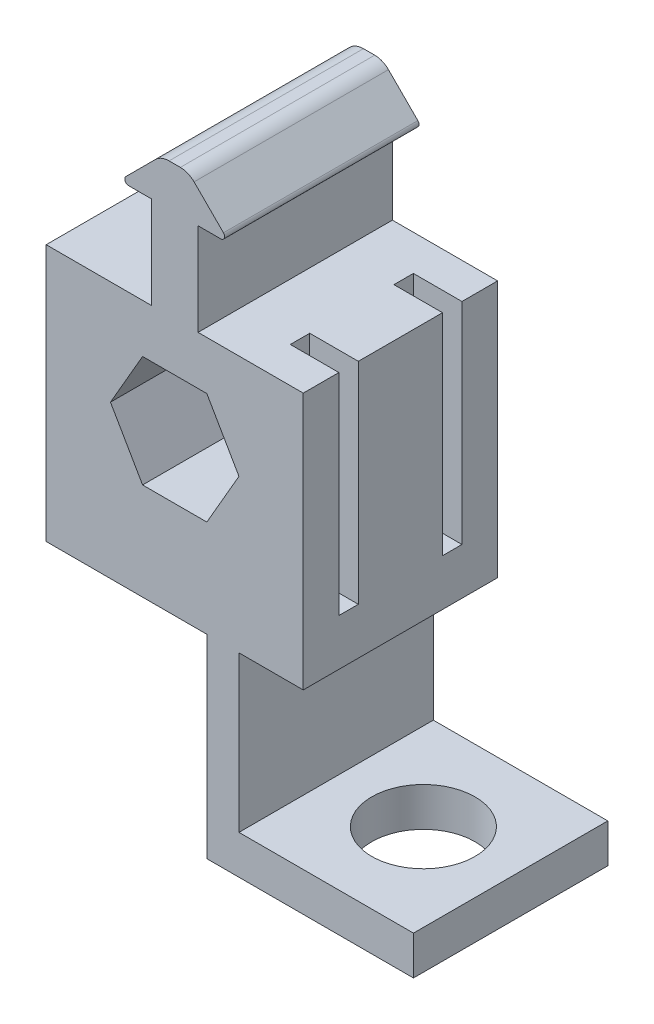
from build123d import *

# Parameters (mm, degrees)
BOSS_EXTRUDE1_DEPTH = 12.7
SKETCH8_W           = 2.54
SKETCH8_H           = 27.5
CUT_EXTRUDE1_DEPTH  = 6.35
SKETCH3_W           = 4.197769469
SKETCH3_H           = 25.4
BOSS_EXTRUDE2_DEPTH = 25.4
SKETCH4_W           = 22.800422122
SKETCH4_H           = 25.4
SKETCH4_R           = 6.75
BOSS_EXTRUDE3_DEPTH = 5.08


with BuildPart() as part:
    # Sketch1 → Boss-Extrude1 (new body, symmetric)
    with BuildSketch(Plane.XY):
        with BuildLine():
            Line((-16.79575, 13.62075), (-16.79575, -19.97075))
            Line((-16.79575, -19.97075), (16.79575, -19.97075))
            Line((16.79575, -19.97075), (16.79575, 13.62075))
            Line((16.79575, 13.62075), (3.048, 13.62075))
            Line((3.048, 13.62075), (3.048, 25.68575))
            Line((3.048, 25.68575), (6.01257951, 25.68575))
            ThreePointArc((6.01257951, 25.68575), (6.481910313, 25.999346816), (6.371789755, 26.552960245))
            Line((6.371789755, 26.552960245), (2.532108776, 30.392641224))
            ThreePointArc((2.532108776, 30.392641224), (1.70807347, 30.943244013), (0.736057552, 31.13659))
            Line((0.736057552, 31.13659), (-0.736057552, 31.13659))
            ThreePointArc((-0.736057552, 31.13659), (-1.70807347, 30.943244013), (-2.532108776, 30.392641224))
            Line((-2.532108776, 30.392641224), (-6.371789755, 26.552960245))
            ThreePointArc((-6.371789755, 26.552960245), (-6.481910313, 25.999346816), (-6.01257951, 25.68575))
            Line((-6.01257951, 25.68575), (-3.048, 25.68575))
            Line((-3.048, 25.68575), (-3.048, 13.62075))
            Line((-3.048, 13.62075), (-16.79575, 13.62075))
        make_face()
        Polygon((-4.19776947, 7.27075), (-8.395538939, 0), (-4.19776947, -7.27075), (4.19776947, -7.27075), (8.395538939, 0), (4.19776947, 7.27075), align=None, mode=Mode.SUBTRACT)
    extrude(amount=BOSS_EXTRUDE1_DEPTH, both=True)

    # Sketch8 → Cut-Extrude1 (cut)
    with BuildSketch(Plane(origin=(16.79575, 0, 0), x_dir=(0, 0, -1), z_dir=(1, 0, 0))):
        with Locations((-6.77, -0.12925)):
            Rectangle(SKETCH8_W, SKETCH8_H)
        with Locations((6.77, -0.12925)):
            Rectangle(SKETCH8_W, SKETCH8_H)
    extrude(amount=-CUT_EXTRUDE1_DEPTH, mode=Mode.SUBTRACT)

    # Sketch3 → Boss-Extrude2 (add)
    with BuildSketch(Plane.XZ.offset(19.97075)):
        with Locations((6.296654204, 0)):
            Rectangle(SKETCH3_W, SKETCH3_H)
    extrude(amount=BOSS_EXTRUDE2_DEPTH)

    # Sketch4 → Boss-Extrude3 (add)
    with BuildSketch(Plane.XZ.offset(45.37075)):
        with Locations((19.79575, 0)):
            Rectangle(SKETCH4_W, SKETCH4_H)
        with Locations((19.79575, 0)):
            Circle(SKETCH4_R, mode=Mode.SUBTRACT)
    extrude(amount=-BOSS_EXTRUDE3_DEPTH)


solid = part.part
